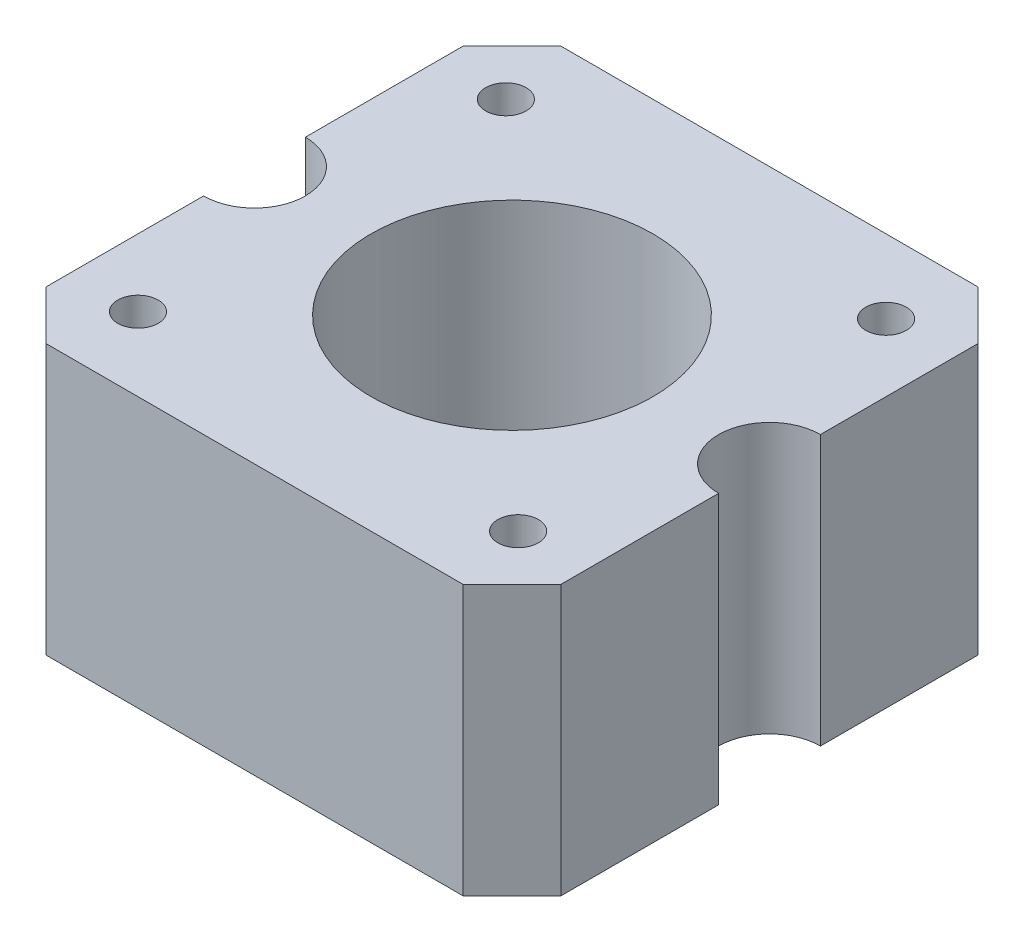
from build123d import *

# Parameters (mm, degrees)
SKETCH1_W                      = 42
SKETCH1_H                      = 42
BOSS_EXTRUDE1_DEPTH            = 22
CUT_EXTRUDE1_REACH             = 24
SKETCH2_R                      = 11.5
SKETCH2_R_2                    = 1.65
CUT_EXTRUDE1_DIRECTION_2_DEPTH = 1
CHAMFER1_SIZE                  = 4
SKETCH3_R                      = 3
CUT_EXTRUDE2_DEPTH             = 1
CUT_EXTRUDE2_DEPTH_BACK        = 5
CUT_EXTRUDE3_REACH             = 24
SKETCH4_R                      = 4.15
CUT_EXTRUDE3_DIRECTION_2_DEPTH = 1


with BuildPart() as part:
    # Sketch1 → Boss-Extrude1 (new body)
    with BuildSketch(Plane(origin=(0, 0, 0), x_dir=(1, 0, 0), z_dir=(0, 1, 0))):
        Rectangle(SKETCH1_W, SKETCH1_H)
    extrude(amount=BOSS_EXTRUDE1_DEPTH)

    # Sketch2 → Cut-Extrude1 (cut, up to next)
    with BuildSketch(Plane(origin=(0, 22, 0), x_dir=(1, 0, 0), z_dir=(0, 1, 0)), mode=Mode.PRIVATE) as cut_extrude1_sk1:
        Circle(SKETCH2_R)
    cut_extrude1_tool1 = extrude(cut_extrude1_sk1.sketch, amount=-CUT_EXTRUDE1_REACH, mode=Mode.PRIVATE) & part.part
    add(cut_extrude1_tool1.solids().sort_by_distance((0, 22, 0))[0], mode=Mode.SUBTRACT)
    # Sketch2 → Cut-Extrude1 (cut, up to next)
    with BuildSketch(Plane(origin=(0, 22, 0), x_dir=(1, 0, 0), z_dir=(0, 1, 0)), mode=Mode.PRIVATE) as cut_extrude1_sk2:
        with Locations((-15.5, 15)):
            Circle(SKETCH2_R_2)
    cut_extrude1_tool2 = extrude(cut_extrude1_sk2.sketch, amount=-CUT_EXTRUDE1_REACH, mode=Mode.PRIVATE) & part.part
    add(cut_extrude1_tool2.solids().sort_by_distance((-15.5, 22, -15))[0], mode=Mode.SUBTRACT)
    # Sketch2 → Cut-Extrude1 (cut, up to next)
    with BuildSketch(Plane(origin=(0, 22, 0), x_dir=(1, 0, 0), z_dir=(0, 1, 0)), mode=Mode.PRIVATE) as cut_extrude1_sk3:
        with Locations((15.5, 15)):
            Circle(SKETCH2_R_2)
    cut_extrude1_tool3 = extrude(cut_extrude1_sk3.sketch, amount=-CUT_EXTRUDE1_REACH, mode=Mode.PRIVATE) & part.part
    add(cut_extrude1_tool3.solids().sort_by_distance((15.5, 22, -15))[0], mode=Mode.SUBTRACT)
    # Sketch2 → Cut-Extrude1 (cut, up to next)
    with BuildSketch(Plane(origin=(0, 22, 0), x_dir=(1, 0, 0), z_dir=(0, 1, 0)), mode=Mode.PRIVATE) as cut_extrude1_sk4:
        with Locations((15.5, -15)):
            Circle(SKETCH2_R_2)
    cut_extrude1_tool4 = extrude(cut_extrude1_sk4.sketch, amount=-CUT_EXTRUDE1_REACH, mode=Mode.PRIVATE) & part.part
    add(cut_extrude1_tool4.solids().sort_by_distance((15.5, 22, 15))[0], mode=Mode.SUBTRACT)
    # Sketch2 → Cut-Extrude1 (cut, up to next)
    with BuildSketch(Plane(origin=(0, 22, 0), x_dir=(1, 0, 0), z_dir=(0, 1, 0)), mode=Mode.PRIVATE) as cut_extrude1_sk5:
        with Locations((-15.5, -15)):
            Circle(SKETCH2_R_2)
    cut_extrude1_tool5 = extrude(cut_extrude1_sk5.sketch, amount=-CUT_EXTRUDE1_REACH, mode=Mode.PRIVATE) & part.part
    add(cut_extrude1_tool5.solids().sort_by_distance((-15.5, 22, 15))[0], mode=Mode.SUBTRACT)

    # Sketch2 → Cut-Extrude1 direction 2 (cut)
    with BuildSketch(Plane(origin=(0, 22, 0), x_dir=(1, 0, 0), z_dir=(0, 1, 0))):
        Circle(SKETCH2_R)
        with Locations((-15.5, 15)):
            Circle(SKETCH2_R_2)
        with Locations((15.5, 15)):
            Circle(SKETCH2_R_2)
        with Locations((15.5, -15)):
            Circle(SKETCH2_R_2)
        with Locations((-15.5, -15)):
            Circle(SKETCH2_R_2)
    extrude(amount=CUT_EXTRUDE1_DIRECTION_2_DEPTH, mode=Mode.SUBTRACT)

    # Chamfer1
    chamfer1_edges = [part.edges().sort_by_distance(p)[0] for p in [
        (21, 11, 21),
        (-21, 11, 21),
        (-21, 11, -21),
        (21, 11, -21),
    ]]
    chamfer(chamfer1_edges, length=CHAMFER1_SIZE)

    # Sketch3 → Cut-Extrude2 (cut, two sides)
    with BuildSketch(Plane.XZ) as cut_extrude2_sk:
        with Locations((-15.5, 15)):
            Circle(SKETCH3_R)
        with Locations((15.5, 15)):
            Circle(SKETCH3_R)
        with Locations((15.5, -15)):
            Circle(SKETCH3_R)
        with Locations((-15.5, -15)):
            Circle(SKETCH3_R)
    extrude(amount=CUT_EXTRUDE2_DEPTH, mode=Mode.SUBTRACT)
    extrude(cut_extrude2_sk.sketch, amount=-CUT_EXTRUDE2_DEPTH_BACK, mode=Mode.SUBTRACT)

    # Sketch4 → Cut-Extrude3 (cut, up to next)
    with BuildSketch(Plane(origin=(0, 22, 0), x_dir=(1, 0, 0), z_dir=(0, 1, 0)), mode=Mode.PRIVATE) as cut_extrude3_sk1:
        with Locations((-21, 0)):
            Circle(SKETCH4_R)
    cut_extrude3_tool1 = extrude(cut_extrude3_sk1.sketch, amount=-CUT_EXTRUDE3_REACH, mode=Mode.PRIVATE) & part.part
    add(cut_extrude3_tool1.solids().sort_by_distance((-21, 22, 0))[0], mode=Mode.SUBTRACT)
    # Sketch4 → Cut-Extrude3 (cut, up to next)
    with BuildSketch(Plane(origin=(0, 22, 0), x_dir=(1, 0, 0), z_dir=(0, 1, 0)), mode=Mode.PRIVATE) as cut_extrude3_sk2:
        with Locations((21, 0)):
            Circle(SKETCH4_R)
    cut_extrude3_tool2 = extrude(cut_extrude3_sk2.sketch, amount=-CUT_EXTRUDE3_REACH, mode=Mode.PRIVATE) & part.part
    add(cut_extrude3_tool2.solids().sort_by_distance((21, 22, 0))[0], mode=Mode.SUBTRACT)

    # Sketch4 → Cut-Extrude3 direction 2 (cut)
    with BuildSketch(Plane(origin=(0, 22, 0), x_dir=(1, 0, 0), z_dir=(0, 1, 0))):
        with Locations((-21, 0)):
            Circle(SKETCH4_R)
        with Locations((21, 0)):
            Circle(SKETCH4_R)
    extrude(amount=CUT_EXTRUDE3_DIRECTION_2_DEPTH, mode=Mode.SUBTRACT)


solid = part.part
